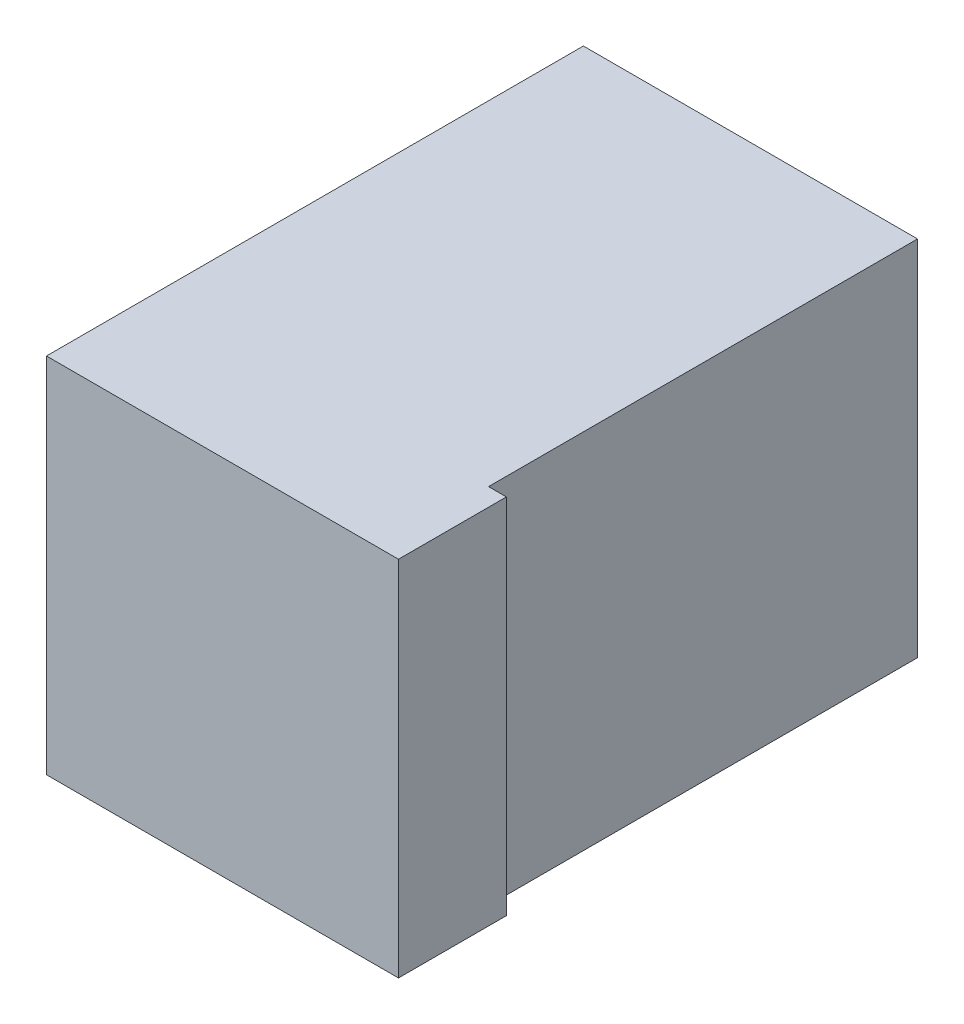
from build123d import *

# Parameters (mm, degrees)
SKETCH1_W           = 99
SKETCH1_H           = 102
BOSS_EXTRUDE1_DEPTH = 151
SKETCH3_W           = 5.02
SKETCH3_H           = 120.65
CUT_EXTRUDE2_DEPTH  = 152.4


with BuildPart() as part:
    # Sketch1 → Boss-Extrude1 (new body)
    with BuildSketch(Plane.XY):
        with Locations((-49.5, -51)):
            Rectangle(SKETCH1_W, SKETCH1_H)
    extrude(amount=BOSS_EXTRUDE1_DEPTH)

    # Sketch3 → Cut-Extrude2 (cut)
    with BuildSketch(Plane.XZ.offset(102)):
        with Locations((-2.51, 60.325)):
            Rectangle(SKETCH3_W, SKETCH3_H)
    extrude(amount=-CUT_EXTRUDE2_DEPTH, mode=Mode.SUBTRACT)


solid = part.part
